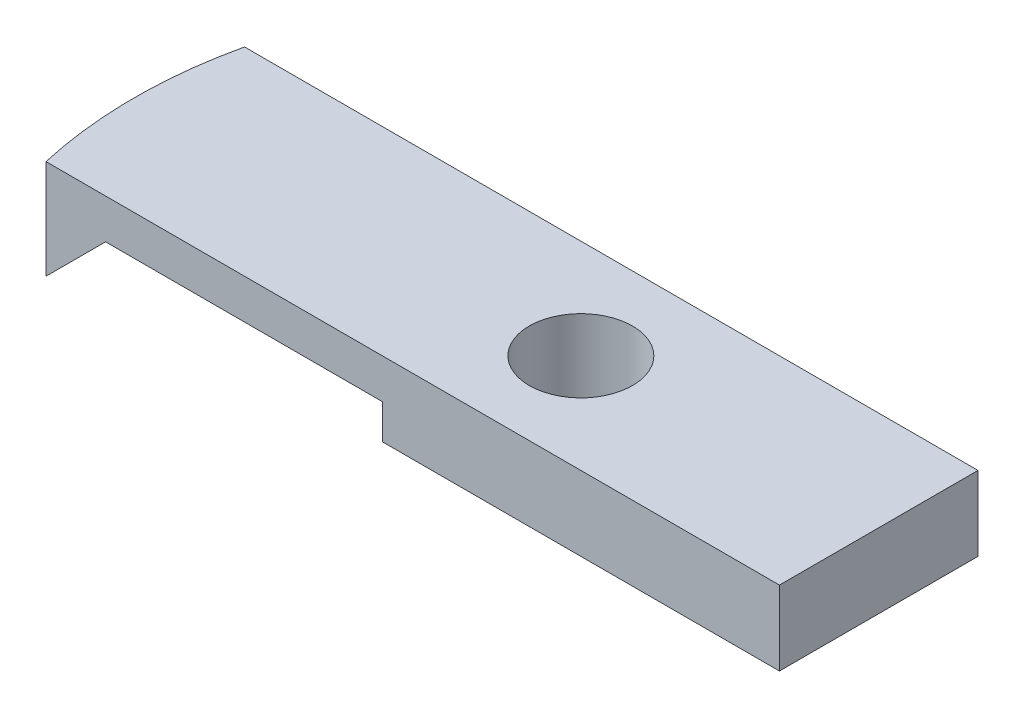
from build123d import *

# Parameters (mm, degrees)
SKETCH1_R           = 3.302
BOSS_EXTRUDE1_DEPTH = 6.35
CUT_EXTRUDE1_DEPTH  = 13.7


with BuildPart() as part:
    # Sketch1 → Boss-Extrude1 (new body)
    with BuildSketch(Plane(origin=(0, 0, 0), x_dir=(1, 0, 0), z_dir=(0, 1, 0))):
        with BuildLine():
            Line((19.05, 6.35), (19.05, -6.35))
            Line((19.05, -6.35), (-27.86051193, -6.35))
            ThreePointArc((-27.86051193, -6.35), (-28.575, 0), (-27.86051193, 6.35))
            Line((-27.86051193, 6.35), (19.05, 6.35))
        make_face()
        Circle(SKETCH1_R, mode=Mode.SUBTRACT)
    extrude(amount=BOSS_EXTRUDE1_DEPTH)

    # Sketch2 → Cut-Extrude1 (cut, through all)
    with BuildSketch(Plane.XY.offset(6.35)):
        Polygon((19.05, 0), (19.05, 1.5875), (-6.35, 1.5875), (-26.27301193, 1.5875), (-27.86051193, 0), align=None)
        Polygon((-26.27301193, 1.5875), (-6.35, 1.5875), (-6.35, 3.81), (-24.05051193, 3.81), align=None)
    extrude(amount=-CUT_EXTRUDE1_DEPTH, mode=Mode.SUBTRACT)


solid = part.part
